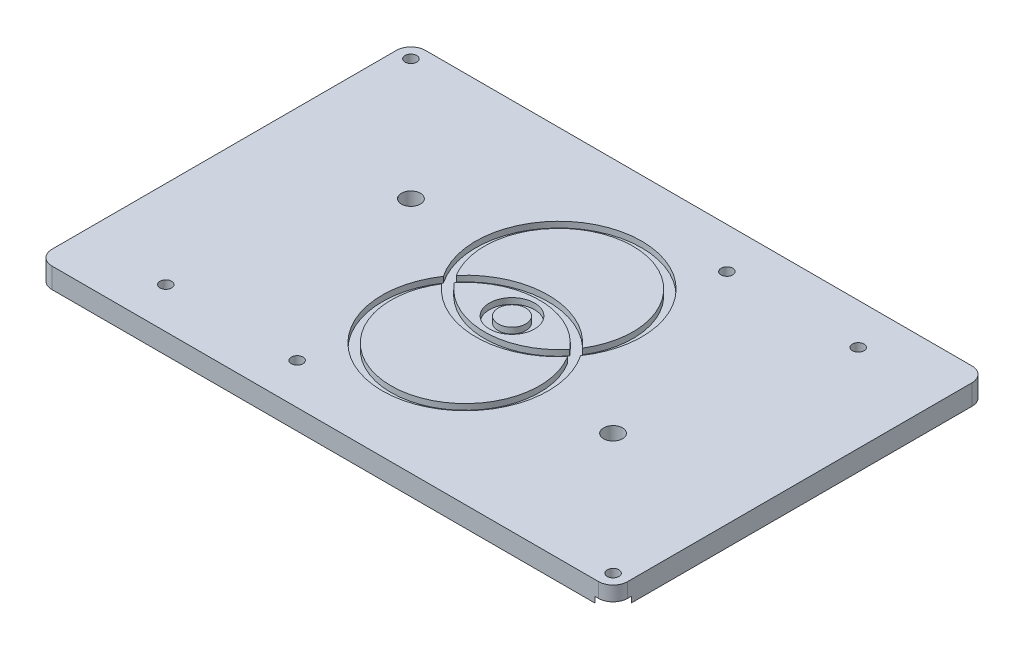
from build123d import *

# Parameters (mm, degrees)
SKETCH1_R           = 2
SKETCH1_R_2         = 3.25
BOSS_EXTRUDE1_DEPTH = 7
SKETCH2_R           = 5.15
CUT_EXTRUDE1_DEPTH  = 2
CUT_EXTRUDE3_DEPTH  = 2


with BuildPart() as part:
    # Sketch1 → Boss-Extrude1 (new body)
    with BuildSketch(Plane(origin=(0, 0, 0), x_dir=(1, 0, 0), z_dir=(0, 1, 0))):
        with BuildLine():
            Line((-118.197336116, 56.752063188), (69.085931957, 56.752063188))
            ThreePointArc((69.085931957, 56.752063188), (72.621465863, 55.287597094), (74.085931957, 51.752063188))
            Line((74.085931957, 51.752063188), (74.085931957, -66.247936812))
            ThreePointArc((74.085931957, -66.247936812), (72.621465863, -69.783470718), (69.085931957, -71.247936812))
            Line((69.085931957, -71.247936812), (-118.197336116, -71.247936812))
            ThreePointArc((-118.197336116, -71.247936812), (-121.732870022, -69.783470718), (-123.197336116, -66.247936812))
            Line((-123.197336116, -66.247936812), (-123.197336116, 51.752063188))
            ThreePointArc((-123.197336116, 51.752063188), (-121.732870022, 55.287597094), (-118.197336116, 56.752063188))
        make_face()
        with Locations(Location((-118.197336116, 51.752063188, 0), (0, 0, 270))):
            Circle(SKETCH1_R, mode=Mode.SUBTRACT)
        with Locations(Location((69.085931957, -66.247936812, 0), (0, 0, 270))):
            Circle(SKETCH1_R, mode=Mode.SUBTRACT)
        with Locations(Location((44.085931957, 42.752063188, 0), (0, 0, 270))):
            Circle(SKETCH1_R, mode=Mode.SUBTRACT)
        with Locations(Location((-0.914068043, 42.752063188, 0), (0, 0, 270))):
            Circle(SKETCH1_R, mode=Mode.SUBTRACT)
        with Locations(Location((-93.197336116, -57.247936812, 0), (0, 0, 270))):
            Circle(SKETCH1_R, mode=Mode.SUBTRACT)
        with Locations(Location((-48.197336116, -57.247936812, 0), (0, 0, 270))):
            Circle(SKETCH1_R, mode=Mode.SUBTRACT)
        with Locations(Location((-76.697336116, 10.252063188, 0), (0, 0, 270))):
            Circle(SKETCH1_R_2, mode=Mode.SUBTRACT)
        with Locations(Location((27.585931957, -24.747936812, 0), (0, 0, 270))):
            Circle(SKETCH1_R_2, mode=Mode.SUBTRACT)
    extrude(amount=BOSS_EXTRUDE1_DEPTH)

    # Sketch2 → Cut-Extrude1 (cut)
    with BuildSketch(Plane.XZ):
        with Locations((-118.197336116, -51.752063188)):
            Circle(SKETCH2_R)
        with Locations(Location((-0.914068043, -42.752063188, 0), (0, 0, 270))):
            Circle(SKETCH2_R)
        with Locations(Location((44.085931957, -42.752063188, 0), (0, 0, 270))):
            Circle(SKETCH2_R)
        with Locations((69.085931957, 66.247936812)):
            Circle(SKETCH2_R)
        with Locations(Location((-48.197336116, 57.247936812, 0), (0, 0, 270))):
            Circle(SKETCH2_R)
        with Locations(Location((-93.197336116, 57.247936812, 0), (0, 0, 270))):
            Circle(SKETCH2_R)
    extrude(amount=-CUT_EXTRUDE1_DEPTH, mode=Mode.SUBTRACT)

    # Sketch4 → Cut-Extrude3 (cut)
    with BuildSketch(Plane(origin=(0, 7, 0), x_dir=(1, 0, 0), z_dir=(0, 1, 0))):
        with BuildLine():
            ThreePointArc((-16.825362278, -7.247936812), (-22.411093503, 0.178960757), (-31.096095238, -3.127086078))
            Line((-31.096095238, -3.127086078), (-28.557891229, -4.726311018))
            ThreePointArc((-28.557891229, -4.726311018), (-23.243375898, -2.703279), (-19.825362278, -7.247936812))
            ThreePointArc((-19.825362278, -7.247936812), (-20.011044267, -8.560262993), (-20.553512929, -9.769562607))
            Line((-20.553512929, -9.769562607), (-18.01530892, -11.368787546))
            ThreePointArc((-18.01530892, -11.368787546), (-17.12880451, -9.392545389), (-16.825362278, -7.247936812))
        make_face()
        with BuildLine():
            Line((-28.557891229, -4.726311018), (-31.096095238, -3.127086078))
            ThreePointArc((-31.096095238, -3.127086078), (-28.676552813, -13.788329971), (-18.01530892, -11.368787546))
            Line((-18.01530892, -11.368787546), (-20.553512929, -9.769562607))
            ThreePointArc((-20.553512929, -9.769562607), (-27.077327874, -11.250125962), (-28.557891229, -4.726311018))
        make_face()
        with BuildLine():
            ThreePointArc((-1.038546315, -7.247936812), (-15.286948513, 35.660240122), (-52.943648692, 10.638218929))
            Line((-52.943648692, 10.638218929), (-50.005532279, 8.78702453))
            ThreePointArc((-50.005532279, 8.78702453), (-17.529440865, 33.223292942), (-2.972559683, -4.723049934))
            ThreePointArc((-2.972559683, -4.723049934), (-19.617614772, 4.759547304), (-38.501589456, 1.538831635))
            Line((-38.501589456, 1.538831635), (-35.563473042, -0.312362764))
            ThreePointArc((-35.563473042, -0.312362764), (-18.963238247, 1.569321693), (-4.772942827, -7.247936812))
            ThreePointArc((-4.772942827, -7.247936812), (-8.774709253, -11.203752107), (-13.547931116, -14.18351086))
            Line((-13.547931116, -14.18351086), (-10.609814702, -16.034705259))
            ThreePointArc((-10.609814702, -16.034705259), (-6.517387874, -13.237701677), (-2.972559683, -9.77282369))
            ThreePointArc((-2.972559683, -9.77282369), (-0.088261351, -16.255690409), (0.89412812, -23.282898154))
            Line((0.89412812, -23.282898154), (3.832244534, -25.134092553))
            ThreePointArc((3.832244534, -25.134092553), (2.894499286, -15.78317183), (-1.038546315, -7.247936812))
        make_face()
        with BuildLine():
            Line((-50.005532279, 8.78702453), (-52.943648692, 10.638218929))
            ThreePointArc((-52.943648692, 10.638218929), (-52.005903444, 1.287298206), (-48.072857843, -7.247936812))
            ThreePointArc((-48.072857843, -7.247936812), (-33.824455645, -50.156113746), (3.832244534, -25.134092553))
            Line((3.832244534, -25.134092553), (0.89412812, -23.282898154))
            ThreePointArc((0.89412812, -23.282898154), (-31.581963293, -47.719166566), (-46.138844475, -9.77282369))
            ThreePointArc((-46.138844475, -9.77282369), (-29.493789386, -19.255420928), (-10.609814702, -16.034705259))
            Line((-10.609814702, -16.034705259), (-13.547931116, -14.18351086))
            ThreePointArc((-13.547931116, -14.18351086), (-30.148165911, -16.065195317), (-44.338461331, -7.247936812))
            ThreePointArc((-44.338461331, -7.247936812), (-40.336694905, -3.292121517), (-35.563473042, -0.312362764))
            Line((-35.563473042, -0.312362764), (-38.501589456, 1.538831635))
            ThreePointArc((-38.501589456, 1.538831635), (-42.594016284, -1.258171947), (-46.138844475, -4.723049934))
            ThreePointArc((-46.138844475, -4.723049934), (-49.023142808, 1.759816785), (-50.005532279, 8.78702453))
        make_face()
    extrude(amount=-CUT_EXTRUDE3_DEPTH, mode=Mode.SUBTRACT)


solid = part.part
